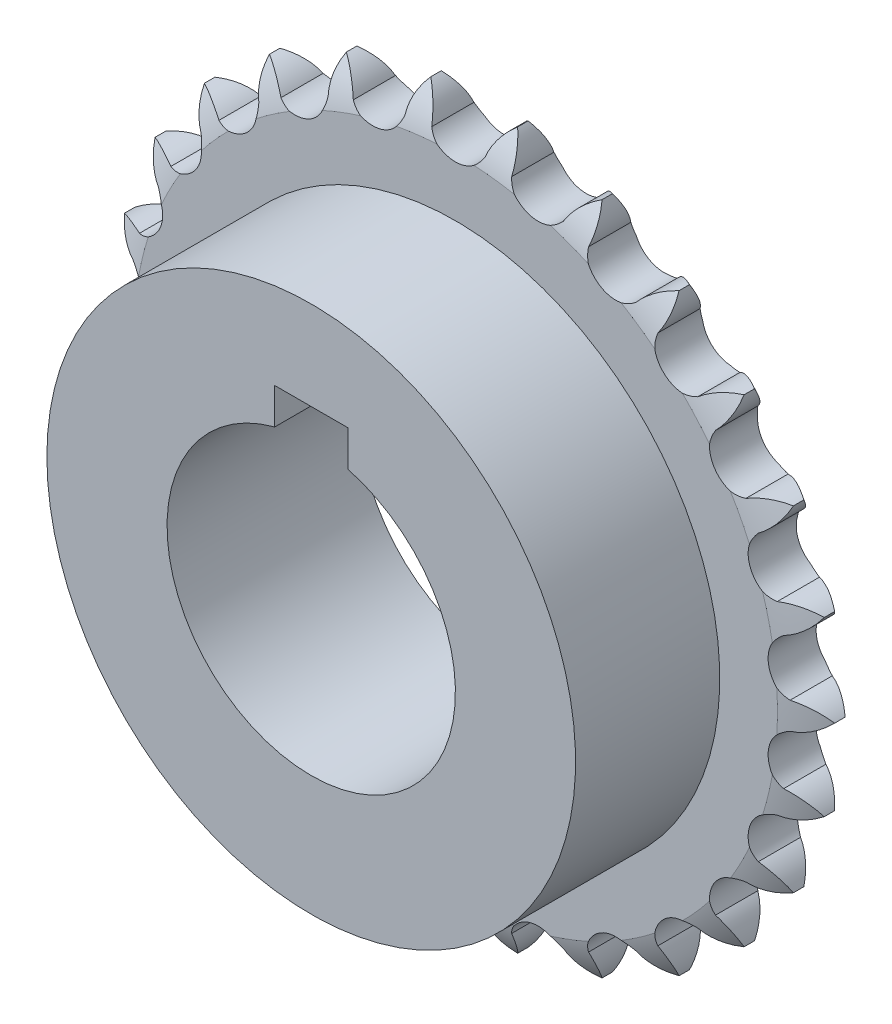
from build123d import *

# Parameters (mm, degrees)
CUT_EXTRUDE2_DEPTH = 26.4
CUT_EXTRUDE3_DEPTH = 26.4000001


with BuildPart() as part:
    # Sketch2 → Revolve1 (revolve)
    with BuildSketch(Plane(origin=(0, 0, 0), x_dir=(0, 0, -1), z_dir=(1, 0, 0))):
        with BuildLine():
            Line((-25.4, 19.05), (0, 19.05))
            Line((0, 19.05), (0, 42.545))
            ThreePointArc((0, 42.545), (-0.958148704, 45.225361135), (-2.4892, 47.625))
            Line((-2.4892, 47.625), (-3.8608, 47.625))
            ThreePointArc((-3.8608, 47.625), (-5.391851296, 45.225361135), (-6.35, 42.545))
            Line((-6.35, 42.545), (-6.35, 34.925))
            Line((-6.35, 34.925), (-25.4, 34.925))
            Line((-25.4, 34.925), (-25.4, 19.05))
        make_face()
    revolve(axis=Axis((0, 0, 0), (0, 0, 1)))

    # Sketch3 → Cut-Extrude2 (cut, through all)
    with BuildSketch(Plane.XY.offset(25.4)):
        with BuildLine():
            ThreePointArc((-7.046542184, 43.295003752), (-6.762319893, 45.407802621), (-5.738972562, 47.277952779))
            ThreePointArc((-5.738972562, 47.277952779), (-11.395856468, 46.241486572), (-16.886563125, 44.530715364))
            ThreePointArc((-16.886563125, 44.530715364), (-15.11141119, 43.350233691), (-13.877994977, 41.611445085))
            ThreePointArc((-13.877994977, 41.611445085), (-9.964109809, 40.431822852), (-7.046542184, 43.295003752))
        make_face()
        with BuildLine():
            ThreePointArc((3.519390109, 43.723277552), (4.300979281, 45.70666348), (5.742146226, 47.277567426))
            ThreePointArc((5.742146226, 47.277567426), (0.001598487, 47.624999973), (-5.738972562, 47.277952779))
            ThreePointArc((-5.738972562, 47.277952779), (-4.297911072, 45.706952093), (-3.516455043, 43.723513703))
            ThreePointArc((-3.516455043, 43.723513703), (0.001397657, 41.64151512), (3.519390109, 43.723277552))
        make_face()
        with BuildLine():
            ThreePointArc((16.889552347, 44.529581702), (11.398960543, 46.240721486), (5.742146226, 47.277567426))
            ThreePointArc((5.742146226, 47.277567426), (6.765368015, 45.407348577), (7.049448477, 43.294530634))
            ThreePointArc((7.049448477, 43.294530634), (9.966823896, 40.43115389), (13.880788241, 41.610513388))
            ThreePointArc((13.880788241, 41.610513388), (15.114321173, 43.349219194), (16.889552347, 44.529581702))
        make_face()
        with BuildLine():
            ThreePointArc((27.055399077, 39.193698547), (22.133856446, 42.169100344), (16.889552347, 44.529581702))
            ThreePointArc((16.889552347, 44.529581702), (17.435468504, 42.468835012), (17.205663675, 40.349426813))
            ThreePointArc((17.205663675, 40.349426813), (19.353014559, 36.871080957), (23.435485415, 37.079497435))
            ThreePointArc((23.435485415, 37.079497435), (25.049273656, 38.472475856), (27.055399077, 39.193698547))
        make_face()
        with BuildLine():
            ThreePointArc((35.648884354, 31.580020096), (31.582413065, 35.646764369), (27.055399077, 39.193698547))
            ThreePointArc((27.055399077, 39.193698547), (27.09228294, 37.062187123), (26.36194824, 35.05936097))
            ThreePointArc((26.36194824, 35.05936097), (27.614478361, 31.168194819), (31.628197361, 30.393555869))
            ThreePointArc((31.628197361, 30.393555869), (33.528453405, 31.359852064), (35.648884354, 31.580020096))
        make_face()
        with BuildLine():
            ThreePointArc((-17.202955058, 40.350581705), (-17.432617615, 42.470005325), (-16.886563125, 44.530715364))
            ThreePointArc((-16.886563125, 44.530715364), (-22.131025666, 42.170586052), (-27.052768019, 39.195514635))
            ThreePointArc((-27.052768019, 39.195514635), (-25.046691018, 38.474157278), (-23.432996288, 37.08107053))
            ThreePointArc((-23.432996288, 37.08107053), (-19.350539432, 36.872380004), (-17.202955058, 40.350581705))
        make_face()
        with BuildLine():
            ThreePointArc((-26.359594714, 35.061130517), (-27.089794966, 37.064005691), (-27.052768019, 39.195514635))
            ThreePointArc((-27.052768019, 39.195514635), (-31.580020096, 35.648884354), (-35.646764369, 31.582413065))
            ThreePointArc((-35.646764369, 31.582413065), (-33.526348204, 31.362102693), (-31.62615703, 30.395678939))
            ThreePointArc((-31.62615703, 30.395678939), (-27.612386038, 31.170048455), (-26.359594714, 35.061130517))
        make_face()
        with BuildLine():
            ThreePointArc((-33.984310538, 27.734053866), (-35.172611902, 29.503980769), (-35.646764369, 31.582413065))
            ThreePointArc((-35.646764369, 31.582413065), (-39.193698547, 27.055399077), (-42.169100344, 22.133856446))
            ThreePointArc((-42.169100344, 22.133856446), (-40.057575896, 22.427396695), (-37.981320481, 21.943800973))
            ThreePointArc((-37.981320481, 21.943800973), (-34.269501135, 23.656226989), (-33.984310538, 27.734053866))
        make_face()
        with BuildLine():
            ThreePointArc((-39.633981763, 18.795174814), (-41.21132448, 20.229291728), (-42.169100344, 22.133856446))
            ThreePointArc((-42.169100344, 22.133856446), (-44.529581702, 16.889552347), (-46.240721486, 11.398960543))
            ThreePointArc((-46.240721486, 11.398960543), (-44.260802881, 12.189291922), (-42.129147643, 12.216629056))
            ThreePointArc((-42.129147643, 12.216629056), (-38.934997391, 14.767591597), (-39.633981763, 18.795174814))
        make_face()
        with BuildLine():
            ThreePointArc((-37.98279344, -21.941251311), (-40.059081314, -22.424707658), (-42.170586052, -22.131025666))
            ThreePointArc((-42.170586052, -22.131025666), (-39.195514635, -27.052768019), (-35.648884354, -31.580020096))
            ThreePointArc((-35.648884354, -31.580020096), (-35.174592367, -29.501619634), (-33.986172195, -27.731772503))
            ThreePointArc((-33.986172195, -27.731772503), (-34.271089055, -23.653926491), (-37.98279344, -21.941251311))
        make_face()
        with BuildLine():
            ThreePointArc((-42.129967627, -12.213800981), (-44.261621025, -12.186320753), (-46.241486572, -11.395856468))
            ThreePointArc((-46.241486572, -11.395856468), (-44.530715364, -16.886563125), (-42.170586052, -22.131025666))
            ThreePointArc((-42.170586052, -22.131025666), (-41.21268234, -20.226525246), (-39.635243357, -18.79251422))
            ThreePointArc((-39.635243357, -18.79251422), (-38.935988623, -14.764977934), (-42.129967627, -12.213800981))
        make_face()
        with BuildLine():
            ThreePointArc((-43.828701231, -1.776528933), (-45.891836206, -1.239709182), (-47.624999973, 0.001598487))
            ThreePointArc((-47.624999973, 0.001598487), (-47.277952779, -5.738972562), (-46.241486572, -11.395856468))
            ThreePointArc((-46.241486572, -11.395856468), (-44.855641018, -9.775938731), (-42.980858243, -8.761103317))
            ThreePointArc((-42.980858243, -8.761103317), (-41.338070059, -5.017942527), (-43.828701231, -1.776528933))
        make_face()
        with BuildLine():
            ThreePointArc((-42.98027003, 8.763988519), (-44.854984677, 9.778949781), (-46.240721486, 11.398960543))
            ThreePointArc((-46.240721486, 11.398960543), (-47.277567426, 5.742146226), (-47.624999973, 0.001598487))
            ThreePointArc((-47.624999973, 0.001598487), (-45.891752883, 1.242789808), (-43.828581877, 1.779471065))
            ThreePointArc((-43.828581877, 1.779471065), (-41.337733121, 5.02071746), (-42.98027003, 8.763988519))
        make_face()
        with BuildLine():
            ThreePointArc((42.170586052, 22.131025666), (39.195514635, 27.052768019), (35.648884354, 31.580020096))
            ThreePointArc((35.648884354, 31.580020096), (35.174592367, 29.501619634), (33.986172195, 27.731772503))
            ThreePointArc((33.986172195, 27.731772503), (34.271089055, 23.653926491), (37.98279344, 21.941251311))
            ThreePointArc((37.98279344, 21.941251311), (40.059081314, 22.424707658), (42.170586052, 22.131025666))
        make_face()
        with BuildLine():
            ThreePointArc((46.241486572, 11.395856468), (44.530715364, 16.886563125), (42.170586052, 22.131025666))
            ThreePointArc((42.170586052, 22.131025666), (41.21268234, 20.226525246), (39.635243357, 18.79251422))
            ThreePointArc((39.635243357, 18.79251422), (38.935988623, 14.764977934), (42.129967627, 12.213800981))
            ThreePointArc((42.129967627, 12.213800981), (44.261621025, 12.186320753), (46.241486572, 11.395856468))
        make_face()
        with BuildLine():
            ThreePointArc((47.625, 0), (47.27785646, 5.73976598), (46.241486572, 11.395856468))
            ThreePointArc((46.241486572, 11.395856468), (44.855641018, 9.775938731), (42.980858243, 8.761103317))
            ThreePointArc((42.980858243, 8.761103317), (41.338070059, 5.017942527), (43.828701231, 1.776528933))
            ThreePointArc((43.828701231, 1.776528933), (45.891836206, 1.239709182), (47.624999973, -0.001598487))
            ThreePointArc((47.624999973, -0.001598487), (47.624999993, -0.000799243), (47.625, 0))
        make_face()
        with BuildLine():
            ThreePointArc((46.240721486, -11.398960543), (47.277567426, -5.742146226), (47.624999973, -0.001598487))
            ThreePointArc((47.624999973, -0.001598487), (45.891752883, -1.242789808), (43.828581877, -1.779471065))
            ThreePointArc((43.828581877, -1.779471065), (41.337733121, -5.02071746), (42.98027003, -8.763988519))
            ThreePointArc((42.98027003, -8.763988519), (44.854984677, -9.778949781), (46.240721486, -11.398960543))
        make_face()
        with BuildLine():
            ThreePointArc((42.169100344, -22.133856446), (44.529581702, -16.889552347), (46.240721486, -11.398960543))
            ThreePointArc((46.240721486, -11.398960543), (44.260802881, -12.189291922), (42.129147643, -12.216629056))
            ThreePointArc((42.129147643, -12.216629056), (38.934997391, -14.767591597), (39.633981763, -18.795174814))
            ThreePointArc((39.633981763, -18.795174814), (41.21132448, -20.229291728), (42.169100344, -22.133856446))
        make_face()
        with BuildLine():
            ThreePointArc((35.646764369, -31.582413065), (39.193698547, -27.055399077), (42.169100344, -22.133856446))
            ThreePointArc((42.169100344, -22.133856446), (40.057575896, -22.427396695), (37.981320481, -21.943800973))
            ThreePointArc((37.981320481, -21.943800973), (34.269501135, -23.656226989), (33.984310538, -27.734053866))
            ThreePointArc((33.984310538, -27.734053866), (35.172611902, -29.503980769), (35.646764369, -31.582413065))
        make_face()
        with BuildLine():
            ThreePointArc((16.886563125, -44.530715364), (22.131025666, -42.170586052), (27.052768019, -39.195514635))
            ThreePointArc((27.052768019, -39.195514635), (25.046691018, -38.474157278), (23.432996288, -37.08107053))
            ThreePointArc((23.432996288, -37.08107053), (19.350539432, -36.872380004), (17.202955058, -40.350581705))
            ThreePointArc((17.202955058, -40.350581705), (17.432617615, -42.470005325), (16.886563125, -44.530715364))
        make_face()
        with BuildLine():
            ThreePointArc((27.052768019, -39.195514635), (31.580020096, -35.648884354), (35.646764369, -31.582413065))
            ThreePointArc((35.646764369, -31.582413065), (33.526348204, -31.362102693), (31.62615703, -30.395678939))
            ThreePointArc((31.62615703, -30.395678939), (27.612386038, -31.170048455), (26.359594714, -35.061130517))
            ThreePointArc((26.359594714, -35.061130517), (27.089794966, -37.064005691), (27.052768019, -39.195514635))
        make_face()
        with BuildLine():
            ThreePointArc((5.738972562, -47.277952779), (11.395856468, -46.241486572), (16.886563125, -44.530715364))
            ThreePointArc((16.886563125, -44.530715364), (15.11141119, -43.350233691), (13.877994977, -41.611445085))
            ThreePointArc((13.877994977, -41.611445085), (9.964109809, -40.431822852), (7.046542184, -43.295003752))
            ThreePointArc((7.046542184, -43.295003752), (6.762319893, -45.407802621), (5.738972562, -47.277952779))
        make_face()
        with BuildLine():
            ThreePointArc((-5.742146226, -47.277567426), (-0.001598487, -47.624999973), (5.738972562, -47.277952779))
            ThreePointArc((5.738972562, -47.277952779), (4.297911072, -45.706952093), (3.516455043, -43.723513703))
            ThreePointArc((3.516455043, -43.723513703), (-0.001397657, -41.64151512), (-3.519390109, -43.723277552))
            ThreePointArc((-3.519390109, -43.723277552), (-4.300979281, -45.70666348), (-5.742146226, -47.277567426))
        make_face()
        with BuildLine():
            ThreePointArc((-13.880788241, -41.610513388), (-15.114321173, -43.349219194), (-16.889552347, -44.529581702))
            ThreePointArc((-16.889552347, -44.529581702), (-11.398960543, -46.240721486), (-5.742146226, -47.277567426))
            ThreePointArc((-5.742146226, -47.277567426), (-6.765368015, -45.407348577), (-7.049448477, -43.294530634))
            ThreePointArc((-7.049448477, -43.294530634), (-9.966823896, -40.43115389), (-13.880788241, -41.610513388))
        make_face()
        with BuildLine():
            ThreePointArc((-23.435485415, -37.079497435), (-25.049273656, -38.472475856), (-27.055399077, -39.193698547))
            ThreePointArc((-27.055399077, -39.193698547), (-22.133856446, -42.169100344), (-16.889552347, -44.529581702))
            ThreePointArc((-16.889552347, -44.529581702), (-17.435468504, -42.468835012), (-17.205663675, -40.349426813))
            ThreePointArc((-17.205663675, -40.349426813), (-19.353014559, -36.871080957), (-23.435485415, -37.079497435))
        make_face()
        with BuildLine():
            ThreePointArc((-31.628197361, -30.393555869), (-33.528453405, -31.359852064), (-35.648884354, -31.580020096))
            ThreePointArc((-35.648884354, -31.580020096), (-31.582413065, -35.646764369), (-27.055399077, -39.193698547))
            ThreePointArc((-27.055399077, -39.193698547), (-27.09228294, -37.062187123), (-26.36194824, -35.05936097))
            ThreePointArc((-26.36194824, -35.05936097), (-27.614478361, -31.168194819), (-31.628197361, -30.393555869))
        make_face()
    extrude(amount=-CUT_EXTRUDE2_DEPTH, mode=Mode.SUBTRACT)

    # Sketch4 → Cut-Extrude3 (cut, through all)
    with BuildSketch(Plane.XY.offset(25.4)):
        with BuildLine():
            Line((-4.826, 23.178370862), (-4.826, 18.428570862))
            ThreePointArc((-4.826, 18.428570862), (0, 19.05), (4.826, 18.428570862))
            Line((4.826, 18.428570862), (4.826, 23.178370862))
            Line((4.826, 23.178370862), (-4.826, 23.178370862))
        make_face()
    extrude(amount=-CUT_EXTRUDE3_DEPTH, mode=Mode.SUBTRACT)


solid = part.part
